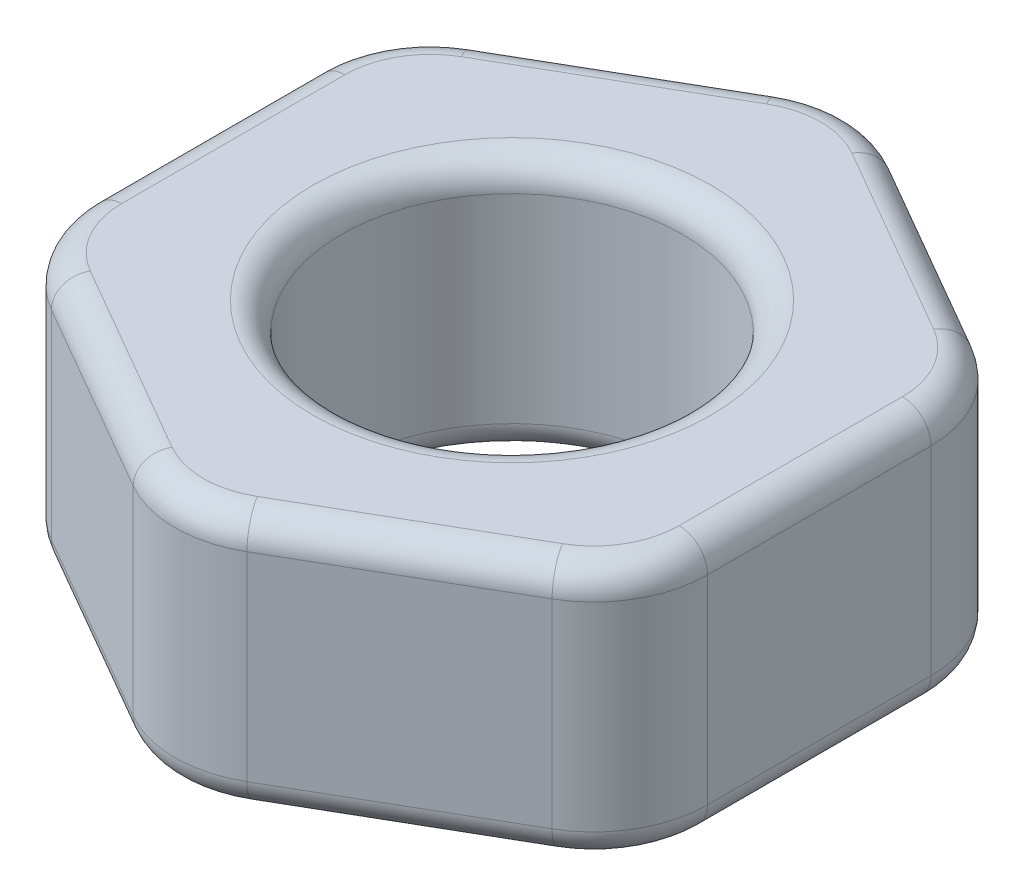
from build123d import *

# Parameters (mm, degrees)
SKETCH1_R           = 1.5
BOSS_EXTRUDE1_DEPTH = 2.25
FILLET1_R           = 1
FILLET2_R           = 0.25


with BuildPart() as part:
    # Sketch1 → Boss-Extrude1 (new body)
    with BuildSketch(Plane(origin=(0, 0, 0), x_dir=(1, 0, 0), z_dir=(0, 1, 0))):
        Polygon((2.7, -1.558845727), (2.7, 1.558845727), (0, 3.117691454), (-2.7, 1.558845727), (-2.7, -1.558845727), (0, -3.117691454), align=None)
        Circle(SKETCH1_R, mode=Mode.SUBTRACT)
    extrude(amount=BOSS_EXTRUDE1_DEPTH)

    # Fillet1
    fillet1_edges = [part.edges().sort_by_distance(p)[0] for p in [
        (0, 1.125, 3.117691454),
        (-2.7, 1.125, 1.558845727),
        (-2.7, 1.125, -1.558845727),
        (0, 1.125, -3.117691454),
        (2.7, 1.125, -1.558845727),
        (2.7, 1.125, 1.558845727),
    ]]
    fillet(fillet1_edges, radius=FILLET1_R)

    # Fillet2
    fillet2_edges = [part.edges().sort_by_distance(p)[0] for p in [
        (-1.5, 0, 0),
        (-1.5, 2.25, 0),
        (-1.35, 0, -2.33826859),
        (-1.35, 2.25, -2.33826859),
        (1.35, 0, 2.33826859),
        (-1.35, 0, 2.33826859),
        (-2.7, 0, 0),
        (1.35, 0, -2.33826859),
        (2.7, 0, 0),
        (0, 0, 2.962990915),
        (2.566025404, 0, 1.481495458),
        (2.566025404, 0, -1.481495458),
        (-2.566025404, 0, 1.481495458),
        (-2.566025404, 0, -1.481495458),
        (0, 0, -2.962990915),
        (1.35, 2.25, -2.33826859),
        (1.35, 2.25, 2.33826859),
        (2.7, 2.25, 0),
        (-2.7, 2.25, 0),
        (-1.35, 2.25, 2.33826859),
        (0, 2.25, 2.962990915),
        (2.566025404, 2.25, 1.481495458),
        (2.566025404, 2.25, -1.481495458),
        (-2.566025404, 2.25, 1.481495458),
        (-2.566025404, 2.25, -1.481495458),
        (0, 2.25, -2.962990915),
    ]]
    fillet(fillet2_edges, radius=FILLET2_R)


solid = part.part
